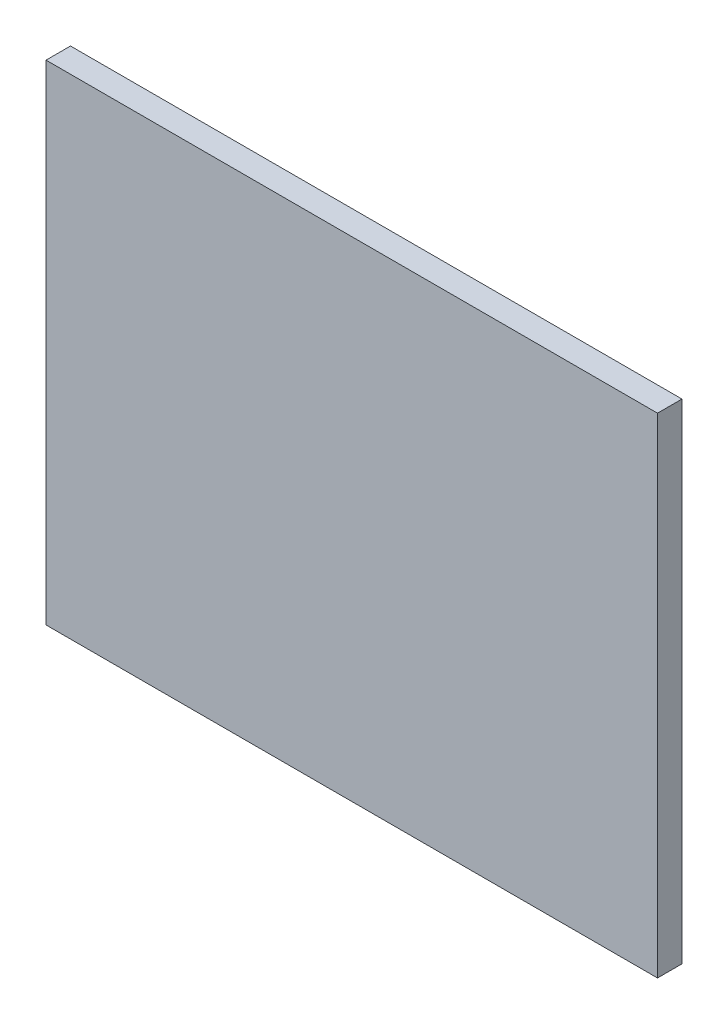
from build123d import *

# Parameters (mm, degrees)
SKIZZE1_W                       = 25
SKIZZE1_H                       = 20
AUFSATZ_LINEAR_AUSTRAGEN1_DEPTH = 1


with BuildPart() as part:
    # Skizze1 → Aufsatz-Linear austragen1 (new body)
    with BuildSketch(Plane.XY):
        Rectangle(SKIZZE1_W, SKIZZE1_H)
    extrude(amount=AUFSATZ_LINEAR_AUSTRAGEN1_DEPTH)


solid = part.part
